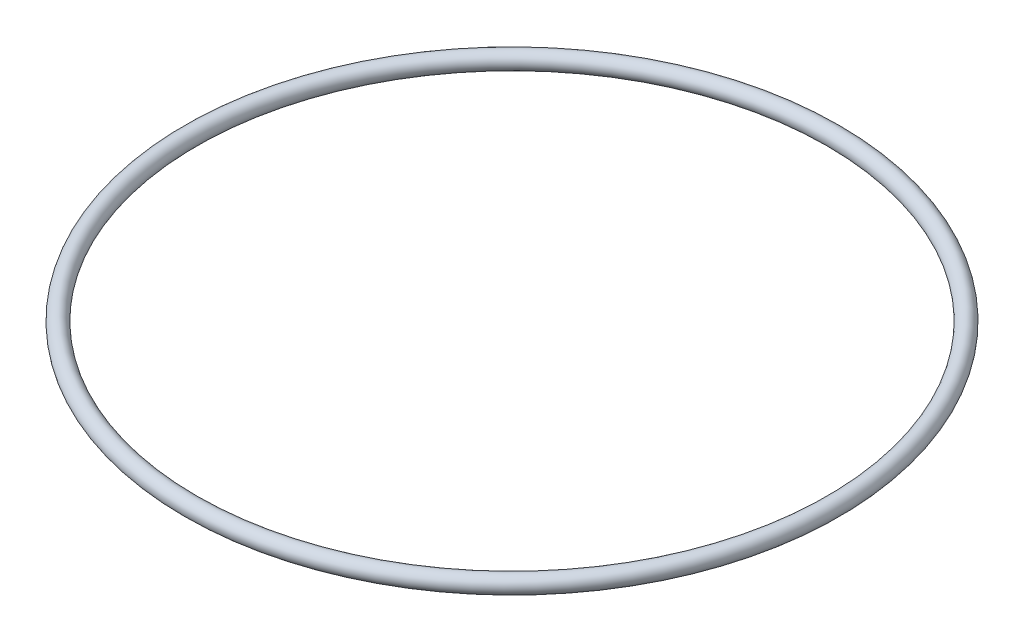
from build123d import *

# Parameters (mm, degrees)
SKETCH1_R = 1


with BuildPart() as part:
    # Sketch1 → Revolve1 (revolve)
    with BuildSketch(Plane.XY, mode=Mode.PRIVATE) as revolve1_sk:
        with Locations((38, 0)):
            Circle(SKETCH1_R)
    revolve(revolve1_sk.sketch.rotate(Axis((0, 0, 0), (0, 1, 0)), 90), axis=Axis((0, 0, 0), (0, 1, 0)))  # turned: the seam where the file's is


solid = part.part
